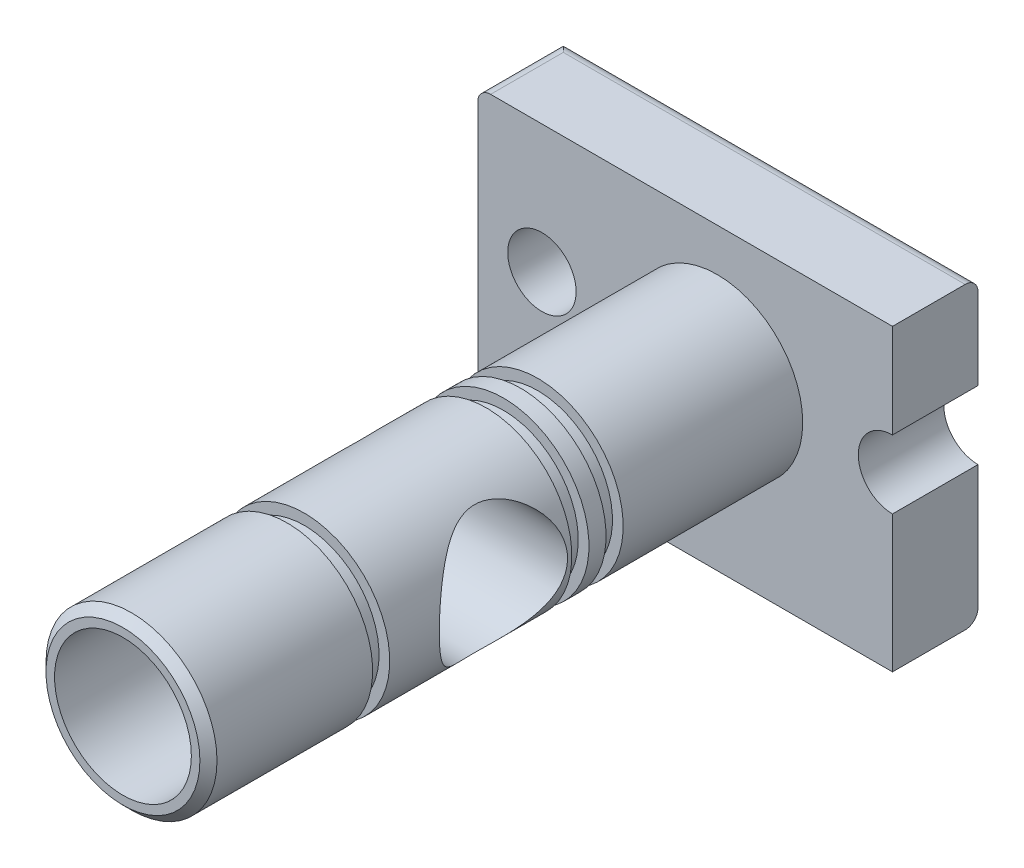
from build123d import *

# Parameters (mm, degrees)
SKETCH1_R               = 8
BOSS_EXTRUDE1_DEPTH     = 20
SKETCH2_R               = 20
BOSS_EXTRUDE2_DEPTH     = 139
SKETCH3_R               = 15
CUT_EXTRUDE1_DEPTH      = 42
CUT_EXTRUDE1_DEPTH_BACK = 57
SKETCH4_W               = 4
SKETCH4_H               = 2.5
SKETCH5_R               = 16
CUT_EXTRUDE2_DEPTH      = 45.4
SKETCH6_R               = 9.5
CUT_EXTRUDE3_DEPTH      = 12
CHAMFER1_SIZE           = 2
FILLET1_R               = 3


with BuildPart() as part:
    # Sketch1 → Boss-Extrude1 (new body)
    with BuildSketch(Plane.XY):
        with BuildLine():
            Line((-56, 30), (41, 30))
            Line((41, 30), (41, 8))
            ThreePointArc((41, 8), (33, 0), (41, -8))
            Line((41, -8), (41, -40))
            Line((41, -40), (-56, -40))
            Line((-56, -40), (-56, 30))
        make_face()
        with Locations((-41, 0)):
            Circle(SKETCH1_R, mode=Mode.SUBTRACT)
    extrude(amount=BOSS_EXTRUDE1_DEPTH)

    # Sketch2 → Boss-Extrude2 (add)
    with BuildSketch(Plane.XY.offset(20)):
        Circle(SKETCH2_R)
    extrude(amount=BOSS_EXTRUDE2_DEPTH)

    # Sketch3 → Cut-Extrude1 (cut, two sides)
    with BuildSketch(Plane(origin=(0, 0, 0), x_dir=(0, 0, -1), z_dir=(1, 0, 0))) as cut_extrude1_sk:
        with Locations((-90, 0)):
            Circle(SKETCH3_R)
    extrude(amount=CUT_EXTRUDE1_DEPTH, mode=Mode.SUBTRACT)
    extrude(cut_extrude1_sk.sketch, amount=-CUT_EXTRUDE1_DEPTH_BACK, mode=Mode.SUBTRACT)

    # Sketch4 → Cut-Revolve1 (revolve, cut)
    with BuildSketch(Plane(origin=(0, 0, 0), x_dir=(0, 0, -1), z_dir=(1, 0, 0))):
        with Locations((-64, 18.75)):
            Rectangle(SKETCH4_W, SKETCH4_H)
        with Locations((-72, 18.75)):
            Rectangle(SKETCH4_W, SKETCH4_H)
        with Locations((-118.6, 18.75)):
            Rectangle(SKETCH4_W, SKETCH4_H)
    revolve(axis=Axis((0, 0, 0), (0, 0, 1)), mode=Mode.SUBTRACT)

    # Sketch5 → Cut-Extrude2 (cut)
    with BuildSketch(Plane.XY.offset(159)):
        Circle(SKETCH5_R)
    extrude(amount=-CUT_EXTRUDE2_DEPTH, mode=Mode.SUBTRACT)

    # Sketch6 → Cut-Extrude3 (cut)
    with BuildSketch(Plane.XY.offset(113.6)):
        Circle(SKETCH6_R)
    extrude(amount=-CUT_EXTRUDE3_DEPTH, mode=Mode.SUBTRACT)

    # Chamfer1
    chamfer1_edges = [part.edges().sort_by_distance(p)[0] for p in [
        (-20, 0, 159),
    ]]
    chamfer(chamfer1_edges, length=CHAMFER1_SIZE)

    # Fillet1
    fillet1_edges = [part.edges().sort_by_distance(p)[0] for p in [
        (-56, 30, 10),
        (-56, -40, 10),
        (-7.5, 30, 0),
        (-7.5, -40, 0),
    ]]
    fillet(fillet1_edges, radius=FILLET1_R)


solid = part.part
